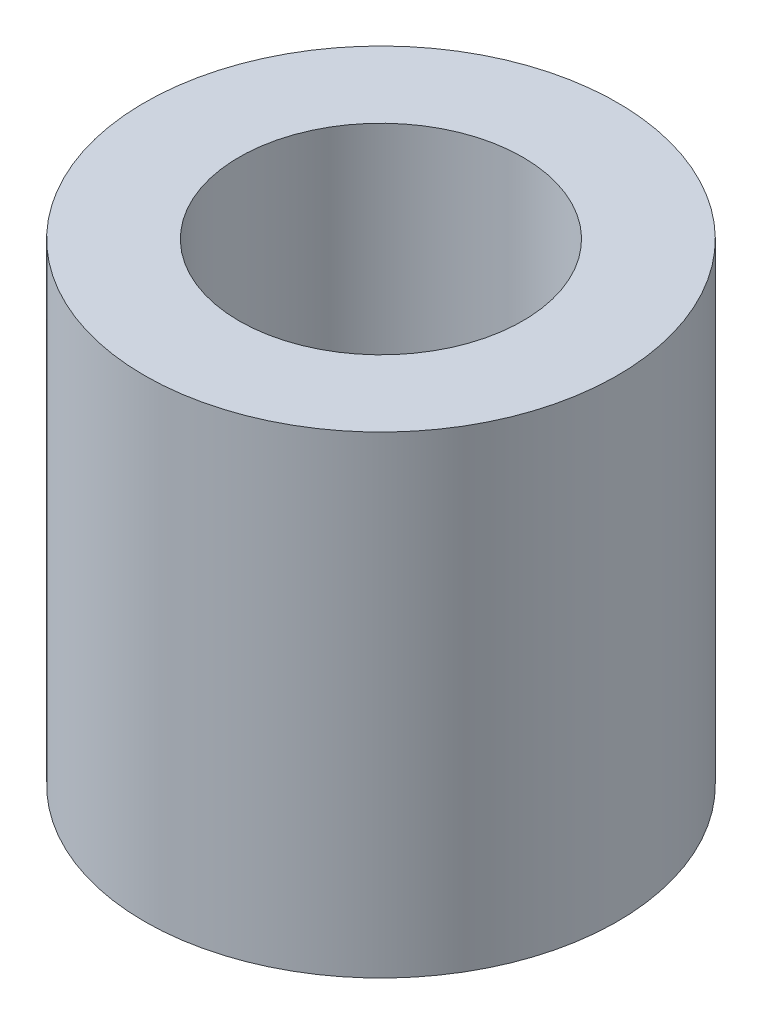
from build123d import *

# Parameters (mm, degrees)
SKETCH1_R           = 2.5
SKETCH1_R_2         = 1.5
BOSS_EXTRUDE1_DEPTH = 5


with BuildPart() as part:
    # Sketch1 → Boss-Extrude1 (new body)
    with BuildSketch(Plane(origin=(0, 0, 0), x_dir=(1, 0, 0), z_dir=(0, 1, 0))):
        Circle(SKETCH1_R)
        Circle(SKETCH1_R_2, mode=Mode.SUBTRACT)
    extrude(amount=BOSS_EXTRUDE1_DEPTH)


solid = part.part
